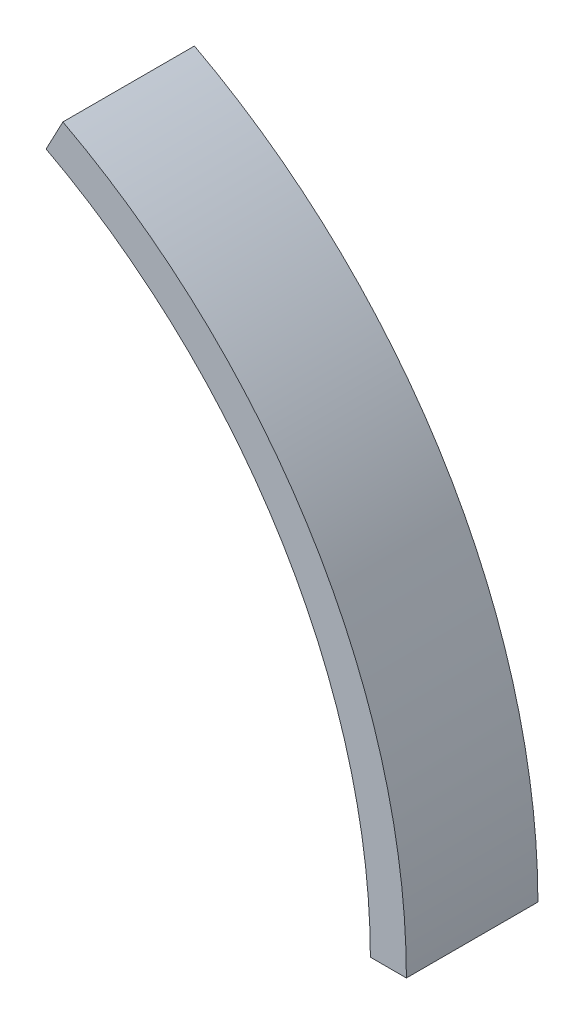
from build123d import *

# Parameters (mm, degrees)
BOSS_EXTRUDE1_DEPTH = 4.6355


with BuildPart() as part:
    # Sketch1 → Boss-Extrude1 (new body, symmetric)
    with BuildSketch(Plane.XY):
        with BuildLine():
            Line((20.0025, 37.909021354), (21.187833333, 40.155481878))
            ThreePointArc((21.187833333, 40.155481878), (38.880378144, 23.445750183), (45.4025, 0))
            Line((45.4025, 0), (42.8625, 0))
            ThreePointArc((42.8625, 0), (36.705252094, 22.134099824), (20.0025, 37.909021354))
        make_face()
    extrude(amount=BOSS_EXTRUDE1_DEPTH, both=True)


solid = part.part
